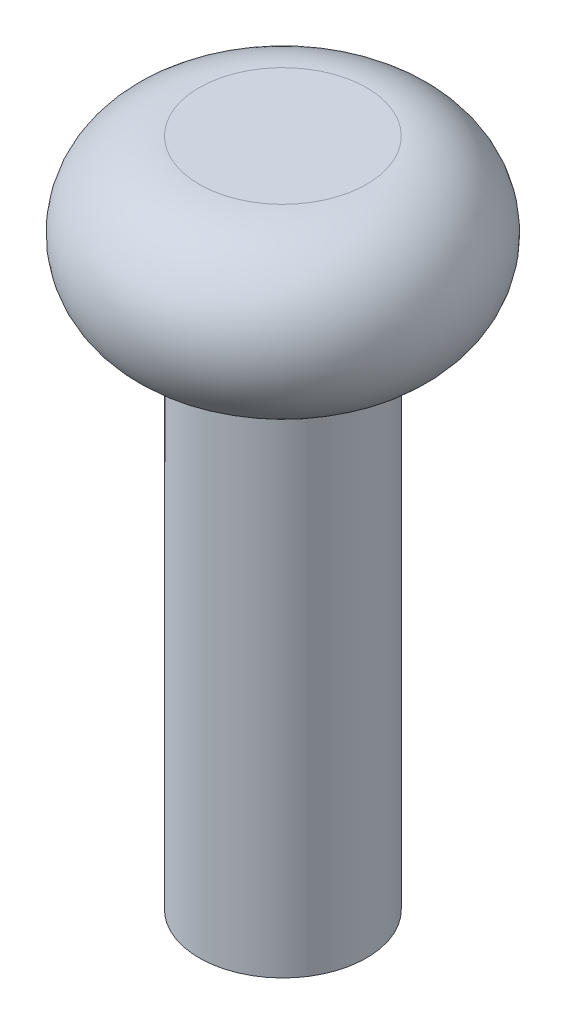
from build123d import *


with BuildPart() as part:
    # Sketch1 → Revolve1 (revolve)
    with BuildSketch(Plane.XY):
        with BuildLine():
            Line((0, 0), (0, 10))
            Line((0, 10), (5, 10))
            ThreePointArc((5, 10), (10, 5), (5, 0))
            Line((5, 0), (5, -30))
            Line((5, -30), (0, -30))
            Line((0, -30), (0, 0))
        make_face()
    revolve(axis=Axis((0, 0, 0), (0, -1, 0)))


solid = part.part
